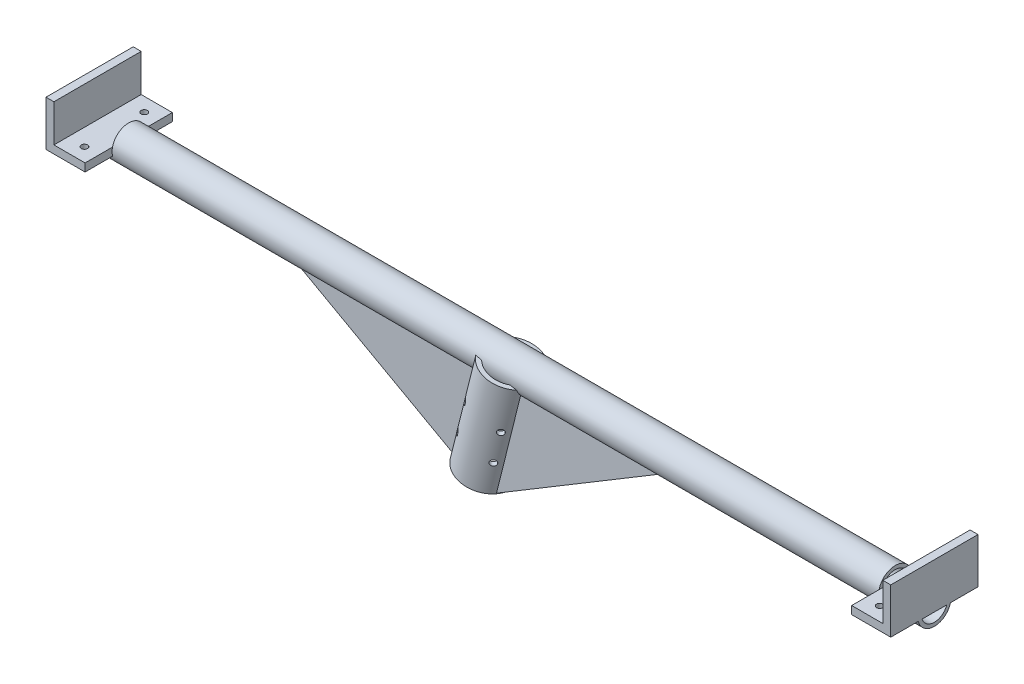
from build123d import *

# Parameters (mm, degrees)
SKETCH1_R                                = 13.335
SKETCH1_R_2                              = 10.465
BOSS_EXTRUDE1_DEPTH                      = 338.85
CUT_EXTRUDE3_START                       = -6.35
CUT_EXTRUDE3_DEPTH                       = 25
SKETCH5_W                                = 25
SKETCH5_H                                = 70
BOSS_EXTRUDE2_DEPTH                      = 6.35
BOSS_EXTRUDE3_START                      = -6.35
SKETCH6_W                                = 6.35
SKETCH6_H                                = 70
BOSS_EXTRUDE3_DEPTH                      = 36.35
F_8_0_199_DIAMETER_HOLE1_D               = 5.0546
F_8_0_199_DIAMETER_HOLE1_DEPTH           = 32.41
SKETCH10_R                               = 21.082
SKETCH10_R_2                             = 17.52
BOSS_EXTRUDE4_DEPTH                      = 85
F_8_0_199_DIAMETER_HOLE2_D               = 5.0546
F_8_0_199_DIAMETER_HOLE2_DEPTH           = 50
F_8_0_199_DIAMETER_HOLE2_ON_FACE_2_D     = 5.0546
F_8_0_199_DIAMETER_HOLE2_ON_FACE_2_DEPTH = 50
F_8_0_199_DIAMETER_HOLE2_ON_FACE_3_D     = 5.0546
F_8_0_199_DIAMETER_HOLE2_ON_FACE_3_DEPTH = 50
F_8_0_199_DIAMETER_HOLE2_ON_FACE_4_D     = 5.0546
F_8_0_199_DIAMETER_HOLE2_ON_FACE_4_DEPTH = 50
RIB3_REACH                               = 353.73
SKETCH17_WALL_W                          = 843.779862378
SKETCH17_WALL_H                          = 20
RIB4_REACH                               = 353.73
SKETCH18_WALL_W                          = 831.548119892
SKETCH18_WALL_H                          = 20


with BuildPart() as part:
    # Sketch1 → Boss-Extrude1 (new body)
    with BuildSketch(Plane(origin=(0, 0, 0), x_dir=(0, 0, -1), z_dir=(1, 0, 0))):
        Circle(SKETCH1_R)
        Circle(SKETCH1_R_2, mode=Mode.SUBTRACT)
    boss_extrude1 = extrude(amount=BOSS_EXTRUDE1_DEPTH)

    # Sketch4 → Cut-Extrude3 (cut)
    with BuildSketch(Plane(origin=(338.85, 0, 0), x_dir=(0, 0, -1), z_dir=(1, 0, 0)).offset(CUT_EXTRUDE3_START)):
        with BuildLine():
            Line((-12.993160701, 3), (12.993160701, 3))
            ThreePointArc((12.993160701, 3), (0, 13.335), (-12.993160701, 3))
        make_face()
    cut_extrude3 = extrude(amount=-CUT_EXTRUDE3_DEPTH, mode=Mode.SUBTRACT)

    # Sketch5 → Boss-Extrude2 (add)
    with BuildSketch(Plane(origin=(0, 3, 0), x_dir=(1, 0, 0), z_dir=(0, 1, 0))):
        with Locations((320, -1e-09)):
            Rectangle(SKETCH5_W, SKETCH5_H)
    boss_extrude2 = extrude(amount=-BOSS_EXTRUDE2_DEPTH)

    # Sketch6 → Boss-Extrude3 (add)
    with BuildSketch(Plane(origin=(0, 3, 0), x_dir=(1, 0, 0), z_dir=(0, 1, 0)).offset(BOSS_EXTRUDE3_START)):
        with Locations((335.675, -1e-09)):
            Rectangle(SKETCH6_W, SKETCH6_H)
    boss_extrude3 = extrude(amount=BOSS_EXTRUDE3_DEPTH)

    # #8 (0.199) Diameter Hole1
    with Locations(Plane(origin=(0, -3.35, 0), x_dir=(-1, 0, 0), z_dir=(0, -1, 0))):
        with Locations((-319, 24), (-319, -24)):
            f_8_0_199_diameter_hole1 = Hole(F_8_0_199_DIAMETER_HOLE1_D / 2, depth=F_8_0_199_DIAMETER_HOLE1_DEPTH)

    # Mirror1: Boss-Extrude1, Cut-Extrude3, Boss-Extrude2, Boss-Extrude3, #8 (0.199) Diameter Hole1 across plane
    add(boss_extrude1.mirror(Plane(origin=(0, 0, 0), x_dir=(0, 0, 1), z_dir=(1, 0, 0))))
    add(cut_extrude3.mirror(Plane(origin=(0, 0, 0), x_dir=(0, 0, 1), z_dir=(1, 0, 0))), mode=Mode.SUBTRACT)
    add(boss_extrude2.mirror(Plane(origin=(0, 0, 0), x_dir=(0, 0, 1), z_dir=(1, 0, 0))))
    add(boss_extrude3.mirror(Plane(origin=(0, 0, 0), x_dir=(0, 0, 1), z_dir=(1, 0, 0))))
    add(f_8_0_199_diameter_hole1.mirror(Plane(origin=(0, 0, 0), x_dir=(0, 0, 1), z_dir=(1, 0, 0))), mode=Mode.SUBTRACT)

    # Sketch10 → Boss-Extrude4 (add)
    with BuildSketch(Plane(origin=(0, 0, 0), x_dir=(0.9702957262759956, -0.24192189559967145, 0), z_dir=(0.24192189559967145, 0.9702957262759956, 0))):
        with Locations(Location((0, 0, 0), (0, 0, 180))):
            Circle(SKETCH10_R)
        with Locations(Location((0, 0, 0), (0, 0, 180))):
            Circle(SKETCH10_R_2, mode=Mode.SUBTRACT)
    extrude(amount=-BOSS_EXTRUDE4_DEPTH)

    # #8 (0.199) Diameter Hole2
    with Locations(Plane(origin=(-28.9797306, -54.611359407, 14.907225161), x_dir=(0.717685601487, 0, 0.696367271932), z_dir=(-0.686102687806, 0.171064612896, 0.707106781187))):
        with Locations((0, -1e-09)):
            Hole(F_8_0_199_DIAMETER_HOLE2_D / 2, depth=F_8_0_199_DIAMETER_HOLE2_DEPTH)

    # #8 (0.199) Diameter Hole2 on face 2
    with Locations(Plane(origin=(-0.050896872, -61.824127746, 14.907225161), x_dir=(0.717685550823, 0, -0.696367324148), z_dir=(0.686102701448, -0.171064925563, 0.707106692309))):
        with Locations((0, 0)):
            Hole(F_8_0_199_DIAMETER_HOLE2_ON_FACE_2_D / 2, depth=F_8_0_199_DIAMETER_HOLE2_ON_FACE_2_DEPTH)

    # #8 (0.199) Diameter Hole2 on face 3
    with Locations(Plane(origin=(-22.93168321, -30.353966251, 14.907225161), x_dir=(0.717685550823, 0, 0.696367324148), z_dir=(-0.686102701448, 0.171064925563, 0.707106692309))):
        with Locations((0, 0)):
            Hole(F_8_0_199_DIAMETER_HOLE2_ON_FACE_3_D / 2, depth=F_8_0_199_DIAMETER_HOLE2_ON_FACE_3_DEPTH)

    # #8 (0.199) Diameter Hole2 on face 4
    with Locations(Plane(origin=(5.997150518, -37.566734589, 14.907225161), x_dir=(0.717685550823, 0, -0.696367324148), z_dir=(0.686102701448, -0.171064925563, 0.707106692309))):
        with Locations((0, 0)):
            Hole(F_8_0_199_DIAMETER_HOLE2_ON_FACE_4_D / 2, depth=F_8_0_199_DIAMETER_HOLE2_ON_FACE_4_DEPTH)

    # Sketch17 wall → Rib3 (add, up to next)
    with BuildSketch(Plane(origin=(59.922310594, -48.955167068, 0), x_dir=(-0.857167300703, -0.515038074908, 0), z_dir=(0.515038074908, -0.857167300703, 0)), mode=Mode.PRIVATE) as rib3_sk1:
        Rectangle(SKETCH17_WALL_W, SKETCH17_WALL_H)
    rib3_tool1 = extrude(rib3_sk1.sketch, amount=-RIB3_REACH, mode=Mode.PRIVATE) - part.part
    add(rib3_tool1.solids().sort_by_distance((59.922310594, -48.955167068, 0))[0])

    # Sketch18 wall → Rib4 (add, up to next)
    with BuildSketch(Plane(origin=(-95.433234599, -43.899526076, 0), x_dir=(0.874619707136, -0.484809620252, 0), z_dir=(0.484809620252, 0.874619707136, 0)), mode=Mode.PRIVATE) as rib4_sk1:
        Rectangle(SKETCH18_WALL_W, SKETCH18_WALL_H)
    rib4_tool1 = extrude(rib4_sk1.sketch, amount=RIB4_REACH, mode=Mode.PRIVATE) - part.part
    add(rib4_tool1.solids().sort_by_distance((-95.433234599, -43.899526076, 0))[0])


solid = part.part
